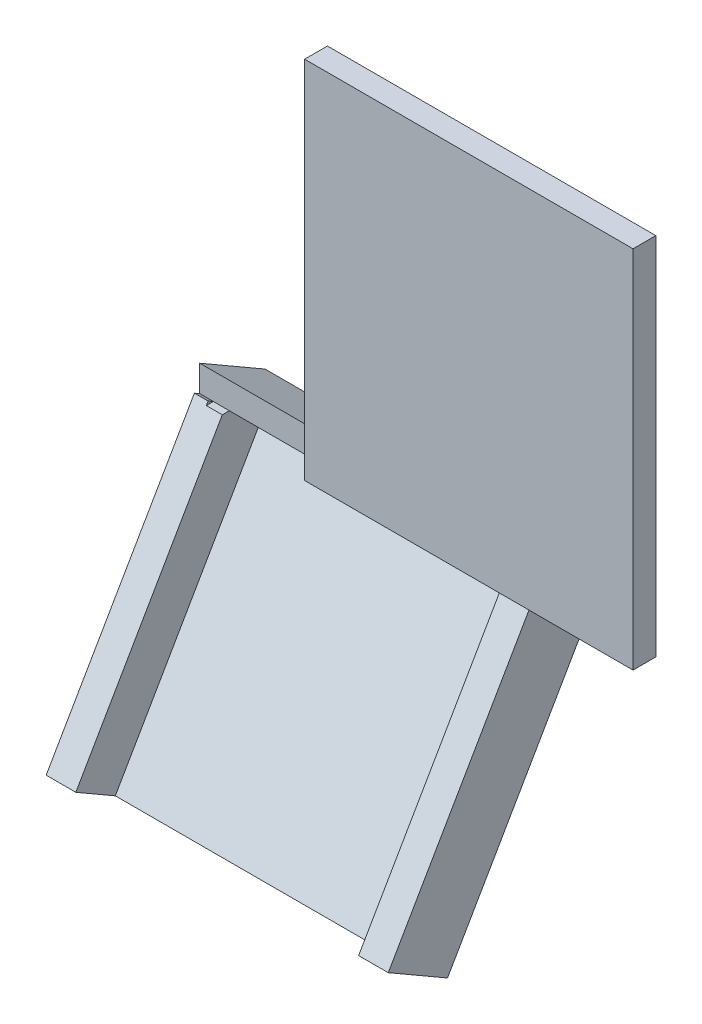
from build123d import *

# Parameters (mm, degrees)
SKIZZE1_W                       = 14.4
SKIZZE1_H                       = 16
AUFSATZ_LINEAR_AUSTRAGEN1_DEPTH = 1
AUFSATZ_LINEAR_AUSTRAGEN4_DEPTH = 15
SKIZZE9_W                       = 1.3
SKIZZE9_H                       = 13
AUFSATZ_LINEAR_AUSTRAGEN5_DEPTH = 2
SKIZZE10_W                      = 1
SKIZZE10_H                      = 16
AUFSATZ_LINEAR_AUSTRAGEN6_DEPTH = 5
SKIZZE13_W                      = 1
SKIZZE13_H                      = 16
SCHNITT_LINEAR_AUSTRAGEN4_DEPTH = 5


with BuildPart() as part:
    # Skizze1 → Aufsatz-Linear austragen1 (new body)
    with BuildSketch(Plane.XY):
        with Locations((7.2, 8)):
            Rectangle(SKIZZE1_W, SKIZZE1_H)
    extrude(amount=AUFSATZ_LINEAR_AUSTRAGEN1_DEPTH)

    # Skizze4 → Aufsatz-Linear austragen4 (add)
    with BuildSketch(Plane(origin=(14.4, 0, 0), x_dir=(0, 0, -1), z_dir=(1, 0, 0))):
        Polygon((0, 1.154700538), (0, 0), (1.5, -0.866025404), (-5, -12.124355653), (-4.133974596, -12.624355653), (2.866025404, -0.5), align=None)
    extrude(amount=-AUFSATZ_LINEAR_AUSTRAGEN4_DEPTH)

    # Skizze9 → Aufsatz-Linear austragen5 (add)
    with BuildSketch(Plane(origin=(0, -0.866025404, -1.5), x_dir=(1, 0, 0), z_dir=(0, 0.49999999999999484, 0.8660254037844418))):
        with Locations((13.75, -6.5)):
            Rectangle(SKIZZE9_W, SKIZZE9_H)
        with Locations((0.05, -6.5)):
            Rectangle(SKIZZE9_W, SKIZZE9_H)
    extrude(amount=AUFSATZ_LINEAR_AUSTRAGEN5_DEPTH)

    # Skizze10 → Aufsatz-Linear austragen6 (add)
    with BuildSketch(Plane(origin=(14.4, 0, 0), x_dir=(0, 0, -1), z_dir=(1, 0, 0))):
        with Locations((-0.5, 8)):
            Rectangle(SKIZZE10_W, SKIZZE10_H)
    extrude(amount=AUFSATZ_LINEAR_AUSTRAGEN6_DEPTH)

    # Skizze13 → Schnitt-Linear austragen4 (cut)
    with BuildSketch(Plane.ZY):
        with Locations((0.5, 8)):
            Rectangle(SKIZZE13_W, SKIZZE13_H)
    extrude(amount=-SCHNITT_LINEAR_AUSTRAGEN4_DEPTH, mode=Mode.SUBTRACT)


solid = part.part
